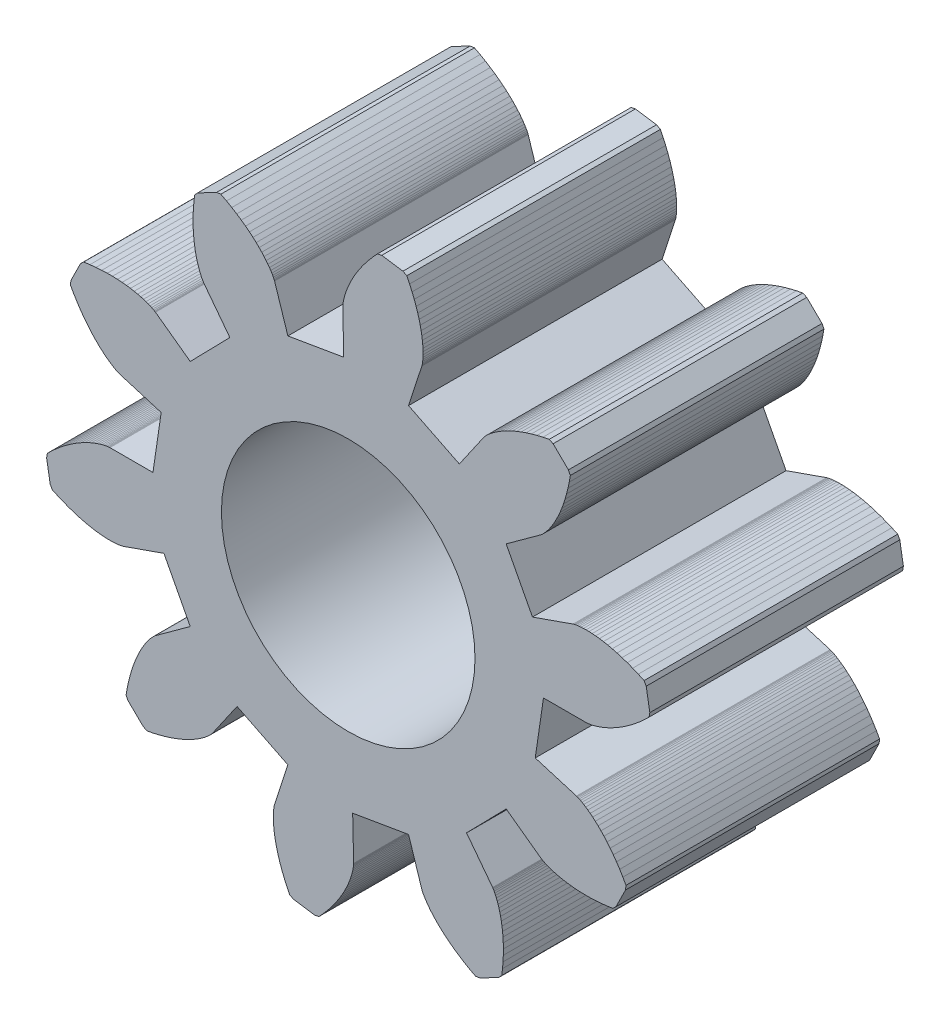
from build123d import *

# Parameters (mm, degrees)
MODEL_R         = 2.5
EXTRUDE_1_DEPTH = 5


with BuildPart() as part:
    # Model → 填料-伸長1 (new body)
    with BuildSketch(Plane.XY):
        Polygon((3.85, 0), (4.6992, 0), (4.7049, 0.0002), (4.7163, 0.001), (4.7334, 0.0029), (4.7561, 0.0061), (4.7843, 0.011), (4.8179, 0.0182), (4.8567, 0.0279), (4.9007, 0.0405), (4.9497, 0.0565), (5.0035, 0.0761), (5.0619, 0.0997), (5.1247, 0.1276), (5.1915, 0.1603), (5.2623, 0.1979), (5.3367, 0.2409), (5.4143, 0.2894), (5.495, 0.3439), (5.5783, 0.4044), (5.664, 0.4714), (5.7517, 0.545), (5.8411, 0.6255), (5.9317, 0.713), (5.9468, 0.7975), (5.876, 1.2136), (5.8338, 1.2884), (5.7194, 1.341), (5.6085, 1.3874), (5.5014, 1.4279), (5.3983, 1.4627), (5.2996, 1.4924), (5.2055, 1.517), (5.1161, 1.5372), (5.0318, 1.5531), (4.9525, 1.5653), (4.8786, 1.574), (4.8102, 1.5796), (4.7473, 1.5826), (4.69, 1.5833), (4.6385, 1.5821), (4.5928, 1.5795), (4.5529, 1.5758), (4.5188, 1.5714), (4.4906, 1.5668), (4.4681, 1.5624), (4.4514, 1.5584), (4.4404, 1.5554), (4.4349, 1.5537), (3.6335, 1.273), (3.1147, 2.263), (3.8017, 2.7621), (3.8062, 2.7657), (3.815, 2.773), (3.8277, 2.7845), (3.8442, 2.8004), (3.8641, 2.821), (3.887, 2.8466), (3.9128, 2.8773), (3.941, 2.9134), (3.9712, 2.9551), (4.0032, 3.0026), (4.0366, 3.056), (4.0709, 3.1155), (4.1058, 3.1812), (4.141, 3.2532), (4.1759, 3.3317), (4.2102, 3.4166), (4.2434, 3.5081), (4.2753, 3.6061), (4.3052, 3.7106), (4.3329, 3.8217), (4.3579, 3.9393), (4.3797, 4.0633), (4.3423, 4.1406), (4.0404, 4.4357), (3.9623, 4.4713), (3.8388, 4.4466), (3.7218, 4.419), (3.6114, 4.3888), (3.5076, 4.3564), (3.4103, 4.3224), (3.3196, 4.287), (3.2355, 4.2508), (3.1579, 4.2141), (3.0867, 4.1774), (3.0218, 4.1409), (2.963, 4.1053), (2.9104, 4.0707), (2.8637, 4.0376), (2.8227, 4.0064), (2.7873, 3.9774), (2.7571, 3.951), (2.7321, 3.9274), (2.712, 3.9071), (2.6965, 3.8903), (2.6852, 3.8773), (2.6781, 3.8683), (2.6746, 3.8638), (2.1913, 3.1655), (1.1897, 3.6616), (1.4521, 4.4692), (1.4537, 4.4747), (1.4564, 4.4858), (1.46, 4.5026), (1.4639, 4.5252), (1.4679, 4.5535), (1.4715, 4.5877), (1.4743, 4.6276), (1.4758, 4.6734), (1.4758, 4.7249), (1.4738, 4.7822), (1.4694, 4.845), (1.4622, 4.9133), (1.4518, 4.987), (1.4379, 5.0659), (1.42, 5.1499), (1.3979, 5.2388), (1.371, 5.3323), (1.3392, 5.4303), (1.3019, 5.5325), (1.259, 5.6387), (1.2101, 5.7485), (1.1549, 5.8617), (1.0792, 5.9021), (0.6615, 5.9634), (0.5774, 5.9464), (0.492, 5.8538), (0.4136, 5.7627), (0.342, 5.6733), (0.277, 5.5861), (0.2184, 5.5014), (0.1658, 5.4195), (0.119, 5.3408), (0.0778, 5.2654), (0.0418, 5.1938), (0.0107, 5.1262), (-0.0159, 5.0629), (-0.0381, 5.004), (-0.0565, 4.9497), (-0.0713, 4.9004), (-0.0829, 4.8561), (-0.0918, 4.817), (-0.0981, 4.7833), (-0.1025, 4.755), (-0.1052, 4.7322), (-0.1066, 4.7151), (-0.1071, 4.7037), (-0.1072, 4.698), (-0.0879, 3.849), (-1.1897, 3.6616), (-1.4521, 4.4692), (-1.4541, 4.4746), (-1.4584, 4.4852), (-1.4654, 4.5008), (-1.4755, 4.5214), (-1.4889, 4.5467), (-1.5061, 4.5764), (-1.5274, 4.6104), (-1.553, 4.6484), (-1.5833, 4.69), (-1.6185, 4.7351), (-1.659, 4.7834), (-1.705, 4.8344), (-1.7567, 4.8879), (-1.8144, 4.9436), (-1.8782, 5.001), (-1.9484, 5.0599), (-2.0251, 5.1198), (-2.1084, 5.1803), (-2.1986, 5.2412), (-2.2957, 5.3018), (-2.3999, 5.3619), (-2.5111, 5.421), (-2.5961, 5.4093), (-2.97, 5.2134), (-3.0281, 5.1501), (-3.0427, 5.025), (-3.0526, 4.9052), (-3.058, 4.7909), (-3.0593, 4.6821), (-3.057, 4.5791), (-3.0514, 4.4819), (-3.0429, 4.3907), (-3.032, 4.3056), (-3.0191, 4.2265), (-3.0045, 4.1535), (-2.9887, 4.0866), (-2.9721, 4.0259), (-2.9551, 3.9712), (-2.9381, 3.9226), (-2.9214, 3.8799), (-2.9056, 3.8431), (-2.8909, 3.8121), (-2.8778, 3.7866), (-2.8666, 3.7666), (-2.8577, 3.752), (-2.8514, 3.7424), (-2.8481, 3.7377), (-2.3335, 3.0623), (-3.1147, 2.263), (-3.8017, 2.7621), (-3.8065, 2.7653), (-3.8162, 2.7713), (-3.8311, 2.7799), (-3.8513, 2.7906), (-3.877, 2.8032), (-3.9084, 2.8171), (-3.9456, 2.8321), (-3.9886, 2.8478), (-4.0376, 2.8637), (-4.0927, 2.8795), (-4.1538, 2.8947), (-4.221, 2.9089), (-4.2943, 2.9218), (-4.3736, 2.933), (-4.459, 2.9419), (-4.5504, 2.9483), (-4.6477, 2.9517), (-4.7507, 2.9517), (-4.8594, 2.9479), (-4.9736, 2.9399), (-5.0932, 2.9273), (-5.2179, 2.9097), (-5.2798, 2.8503), (-5.4671, 2.472), (-5.4769, 2.3867), (-5.4153, 2.2769), (-5.3528, 2.1741), (-5.29, 2.0784), (-5.2271, 1.9897), (-5.1647, 1.9077), (-5.103, 1.8324), (-5.0426, 1.7636), (-4.9837, 1.7011), (-4.9267, 1.6447), (-4.872, 1.5942), (-4.82, 1.5494), (-4.7708, 1.5101), (-4.7249, 1.4758), (-4.6826, 1.4465), (-4.6441, 1.4217), (-4.6096, 1.4013), (-4.5795, 1.3848), (-4.5539, 1.3719), (-4.5331, 1.3623), (-4.5173, 1.3557), (-4.5066, 1.3516), (-4.5012, 1.3498), (-3.6878, 1.1058), (-3.85, 0), (-4.6992, 0), (-4.7049, -0.0002), (-4.7163, -0.001), (-4.7334, -0.0029), (-4.7561, -0.0061), (-4.7843, -0.011), (-4.8179, -0.0182), (-4.8567, -0.0279), (-4.9007, -0.0405), (-4.9497, -0.0565), (-5.0035, -0.0761), (-5.0619, -0.0997), (-5.1247, -0.1276), (-5.1915, -0.1603), (-5.2623, -0.1979), (-5.3367, -0.2409), (-5.4143, -0.2894), (-5.495, -0.3439), (-5.5783, -0.4044), (-5.664, -0.4714), (-5.7517, -0.545), (-5.8411, -0.6255), (-5.9317, -0.713), (-5.9468, -0.7975), (-5.876, -1.2136), (-5.8338, -1.2884), (-5.7194, -1.341), (-5.6085, -1.3874), (-5.5014, -1.4279), (-5.3983, -1.4627), (-5.2996, -1.4924), (-5.2055, -1.517), (-5.1161, -1.5372), (-5.0318, -1.5531), (-4.9525, -1.5653), (-4.8786, -1.574), (-4.8102, -1.5796), (-4.7473, -1.5826), (-4.69, -1.5833), (-4.6385, -1.5821), (-4.5928, -1.5795), (-4.5529, -1.5758), (-4.5188, -1.5714), (-4.4906, -1.5668), (-4.4681, -1.5624), (-4.4514, -1.5584), (-4.4404, -1.5554), (-4.4349, -1.5537), (-3.6335, -1.273), (-3.1147, -2.263), (-3.8017, -2.7621), (-3.8062, -2.7657), (-3.815, -2.773), (-3.8277, -2.7845), (-3.8442, -2.8004), (-3.8641, -2.821), (-3.887, -2.8466), (-3.9128, -2.8773), (-3.941, -2.9134), (-3.9712, -2.9551), (-4.0032, -3.0026), (-4.0366, -3.056), (-4.0709, -3.1155), (-4.1058, -3.1812), (-4.141, -3.2532), (-4.1759, -3.3317), (-4.2102, -3.4166), (-4.2434, -3.5081), (-4.2753, -3.6061), (-4.3052, -3.7106), (-4.3329, -3.8217), (-4.3579, -3.9393), (-4.3797, -4.0633), (-4.3423, -4.1406), (-4.0404, -4.4357), (-3.9623, -4.4713), (-3.8388, -4.4466), (-3.7218, -4.419), (-3.6114, -4.3888), (-3.5076, -4.3564), (-3.4103, -4.3224), (-3.3196, -4.287), (-3.2355, -4.2508), (-3.1579, -4.2141), (-3.0867, -4.1774), (-3.0218, -4.1409), (-2.963, -4.1053), (-2.9104, -4.0707), (-2.8637, -4.0376), (-2.8227, -4.0064), (-2.7873, -3.9774), (-2.7571, -3.951), (-2.7321, -3.9274), (-2.712, -3.9071), (-2.6965, -3.8903), (-2.6852, -3.8773), (-2.6781, -3.8683), (-2.6746, -3.8638), (-2.1913, -3.1655), (-1.1897, -3.6616), (-1.4521, -4.4692), (-1.4537, -4.4747), (-1.4564, -4.4858), (-1.46, -4.5026), (-1.4639, -4.5252), (-1.4679, -4.5535), (-1.4715, -4.5877), (-1.4743, -4.6276), (-1.4758, -4.6734), (-1.4758, -4.7249), (-1.4738, -4.7822), (-1.4694, -4.845), (-1.4622, -4.9133), (-1.4518, -4.987), (-1.4379, -5.0659), (-1.42, -5.1499), (-1.3979, -5.2388), (-1.371, -5.3323), (-1.3392, -5.4303), (-1.3019, -5.5325), (-1.259, -5.6387), (-1.2101, -5.7485), (-1.1549, -5.8617), (-1.0792, -5.9021), (-0.6615, -5.9634), (-0.5774, -5.9464), (-0.492, -5.8538), (-0.4136, -5.7627), (-0.342, -5.6733), (-0.277, -5.5861), (-0.2184, -5.5014), (-0.1658, -5.4195), (-0.119, -5.3408), (-0.0778, -5.2654), (-0.0418, -5.1938), (-0.0107, -5.1262), (0.0159, -5.0629), (0.0381, -5.004), (0.0565, -4.9497), (0.0713, -4.9004), (0.0829, -4.8561), (0.0918, -4.817), (0.0981, -4.7833), (0.1025, -4.755), (0.1052, -4.7322), (0.1066, -4.7151), (0.1071, -4.7037), (0.1072, -4.698), (0.0879, -3.849), (1.1897, -3.6616), (1.4521, -4.4692), (1.4541, -4.4746), (1.4584, -4.4852), (1.4654, -4.5008), (1.4755, -4.5214), (1.4889, -4.5467), (1.5061, -4.5764), (1.5274, -4.6104), (1.553, -4.6484), (1.5833, -4.69), (1.6185, -4.7351), (1.659, -4.7834), (1.705, -4.8344), (1.7567, -4.8879), (1.8144, -4.9436), (1.8782, -5.001), (1.9484, -5.0599), (2.0251, -5.1198), (2.1084, -5.1803), (2.1986, -5.2412), (2.2957, -5.3018), (2.3999, -5.3619), (2.5111, -5.421), (2.5961, -5.4093), (2.97, -5.2134), (3.0281, -5.1501), (3.0427, -5.025), (3.0526, -4.9052), (3.058, -4.7909), (3.0593, -4.6821), (3.057, -4.5791), (3.0514, -4.4819), (3.0429, -4.3907), (3.032, -4.3056), (3.0191, -4.2265), (3.0045, -4.1535), (2.9887, -4.0866), (2.9721, -4.0259), (2.9551, -3.9712), (2.9381, -3.9226), (2.9214, -3.8799), (2.9056, -3.8431), (2.8909, -3.8121), (2.8778, -3.7866), (2.8666, -3.7666), (2.8577, -3.752), (2.8514, -3.7424), (2.8481, -3.7377), (2.3335, -3.0623), (3.1147, -2.263), (3.8017, -2.7621), (3.8065, -2.7653), (3.8162, -2.7713), (3.8311, -2.7799), (3.8513, -2.7906), (3.877, -2.8032), (3.9084, -2.8171), (3.9456, -2.8321), (3.9886, -2.8478), (4.0376, -2.8637), (4.0927, -2.8795), (4.1538, -2.8947), (4.221, -2.9089), (4.2943, -2.9218), (4.3736, -2.933), (4.459, -2.9419), (4.5504, -2.9483), (4.6477, -2.9517), (4.7507, -2.9517), (4.8594, -2.9479), (4.9736, -2.9399), (5.0932, -2.9273), (5.2179, -2.9097), (5.2798, -2.8503), (5.4671, -2.472), (5.4769, -2.3867), (5.4153, -2.2769), (5.3528, -2.1741), (5.29, -2.0784), (5.2271, -1.9897), (5.1647, -1.9077), (5.103, -1.8324), (5.0426, -1.7636), (4.9837, -1.7011), (4.9267, -1.6447), (4.872, -1.5942), (4.82, -1.5494), (4.7708, -1.5101), (4.7249, -1.4758), (4.6826, -1.4465), (4.6441, -1.4217), (4.6096, -1.4013), (4.5795, -1.3848), (4.5539, -1.3719), (4.5331, -1.3623), (4.5173, -1.3557), (4.5066, -1.3516), (4.5012, -1.3498), (3.6878, -1.1058), align=None)
        Circle(MODEL_R, mode=Mode.SUBTRACT)
    extrude(amount=EXTRUDE_1_DEPTH)


solid = part.part
